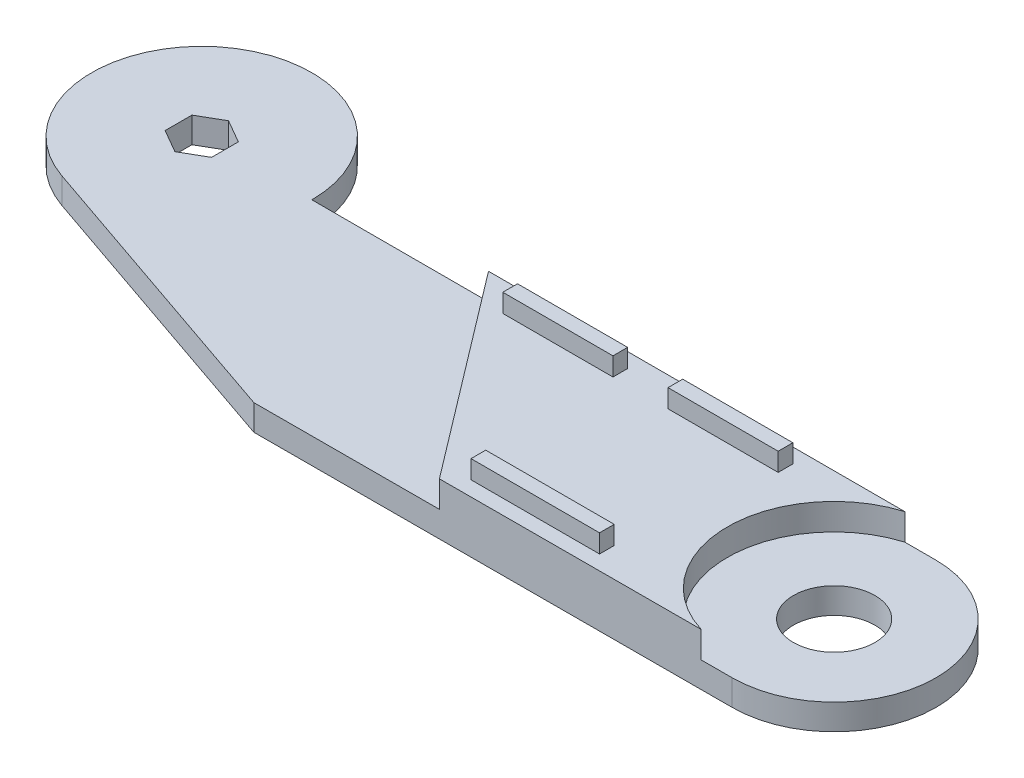
from build123d import *

# Parameters (mm, degrees)
EXTRUDE_1_DEPTH     = 7
CUT_EXTRUDE_1_DEPTH = 9
EXTRUDE_5_DEPTH     = 7.2
SKETCH_14_R         = 11.1
CUT_EXTRUDE_2_DEPTH = 235.901017342
SKETCH_15_W         = 30
SKETCH_15_H         = 4
SKETCH_15_W_2       = 35
EXTRUDE_6_DEPTH     = 5
CUT_EXTRUDE_3_DEPTH = 7.2


with BuildPart() as part:
    # Эскиз1 → Бобышка-Вытянуть1 (new body)
    with BuildSketch(Plane(origin=(0, 0, 0), x_dir=(1, 0, 0), z_dir=(0, 1, 0))):
        with BuildLine():
            Line((199.917837119, 0), (30, 0))
            ThreePointArc((30, 0), (-17.429967854, 24.417129656), (-9.746414708, -28.372652332))
            Line((-9.746414708, -28.372652332), (69.918056204, -55.738545445))
            Line((69.918056204, -55.738545445), (199.917837119, -55.499878365))
            ThreePointArc((199.917837119, -55.499878365), (227.75, -27.75), (199.917837119, -0.000121635))
            Line((199.917837119, -0.000121635), (199.917837119, 0))
        make_face()
    extrude(amount=EXTRUDE_1_DEPTH)

    # Эскиз10 → Вырез-Вытянуть1 (cut)
    with BuildSketch(Plane.XZ):
        Polygon((0, 7.3), (-6.321985448, 3.65), (-6.321985448, -3.65), (0, -7.3), (6.321985448, -3.65), (6.321985448, 3.65), align=None)
    extrude(amount=-CUT_EXTRUDE_1_DEPTH, mode=Mode.SUBTRACT)

    # Эскиз11 → Бобышка-Вытянуть5 (add)
    with BuildSketch(Plane(origin=(0, 7, 0), x_dir=(1, 0, 0), z_dir=(0, 1, 0))):
        with BuildLine():
            ThreePointArc((191.546705266, -55.515246957), (170.918554023, -27.776478596), (191.495899106, 0))
            Line((191.495899106, 0), (69.918541879, 0))
            Line((69.918541879, 0), (69.918541879, -55.738544553))
            Line((69.918541879, -55.738544553), (191.546705266, -55.515246957))
        make_face()
    extrude(amount=EXTRUDE_5_DEPTH)

    # Эскиз14 → Вырез-Вытянуть2 (cut, through all)
    with BuildSketch(Plane.XZ):
        with Locations(Location((200, 27.75, 0), (0, 0, 270))):
            Circle(SKETCH_14_R)
    extrude(amount=-CUT_EXTRUDE_2_DEPTH, mode=Mode.SUBTRACT)

    # Эскиз15 → Бобышка-Вытянуть6 (add)
    with BuildSketch(Plane(origin=(0, 14.2, 0), x_dir=(1, 0, 0), z_dir=(0, 1, 0))):
        with Locations((105, -6)):
            Rectangle(SKETCH_15_W, SKETCH_15_H)
        with Locations((150, -6)):
            Rectangle(SKETCH_15_W, SKETCH_15_H)
        with Locations((142.42, -49.573303801)):
            Rectangle(SKETCH_15_W_2, SKETCH_15_H)
    extrude(amount=EXTRUDE_6_DEPTH)

    # Эскиз16 → Вырез-Вытянуть3 (cut)
    with BuildSketch(Plane(origin=(0, 14.2, 0), x_dir=(1, 0, 0), z_dir=(0, 1, 0))):
        Polygon((78.100396808, 0), (69.918541879, 0), (69.918541879, -55.738544553), (120.375042432, -55.645911276), align=None)
    extrude(amount=-CUT_EXTRUDE_3_DEPTH, mode=Mode.SUBTRACT)


solid = part.part
